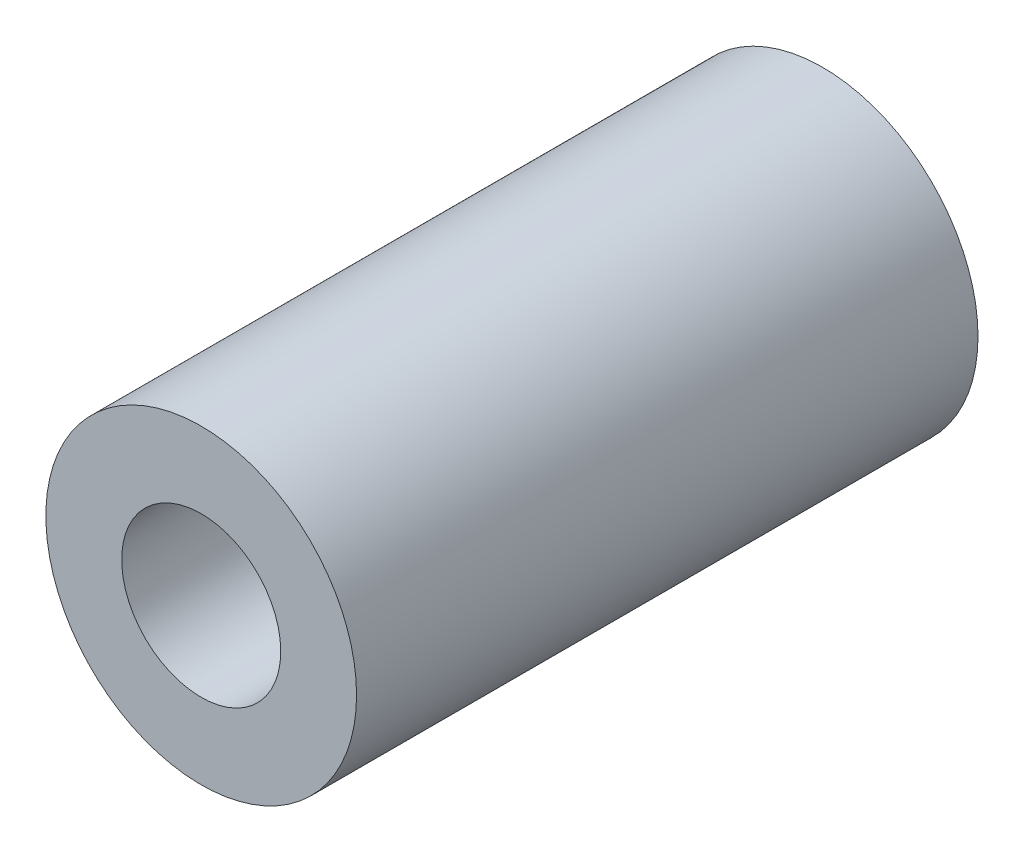
from build123d import *

# Parameters (mm, degrees)
SKETCH1_R      = 4.7625
SKETCH1_R_2    = 2.4384
EXTRUDE1_DEPTH = 9.525


with BuildPart() as part:
    # Sketch1 → Extrude1 (new body, symmetric)
    with BuildSketch(Plane.XY):
        Circle(SKETCH1_R)
        Circle(SKETCH1_R_2, mode=Mode.SUBTRACT)
    extrude(amount=EXTRUDE1_DEPTH, both=True)


solid = part.part
